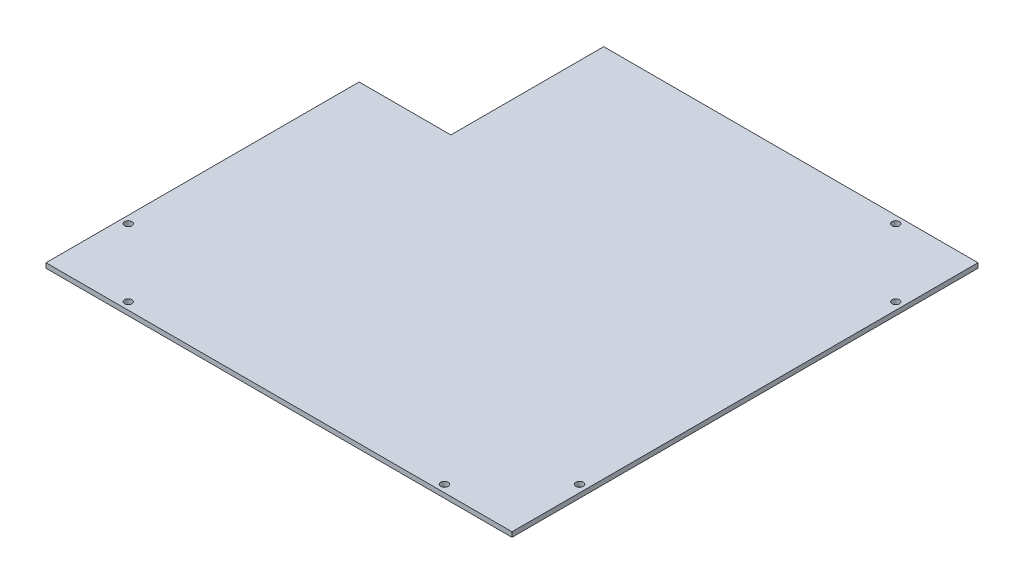
from build123d import *

# Parameters (mm, degrees)
SKETCH1_W           = 152.4
SKETCH1_H           = 152.4
SKETCH1_R           = 1.2
BOSS_EXTRUDE1_DEPTH = 1.5748
SKETCH2_W           = 30
SKETCH2_H           = 50
CUT_EXTRUDE1_DEPTH  = 2.5748


with BuildPart() as part:
    # Sketch1 → Boss-Extrude1 (new body)
    with BuildSketch(Plane(origin=(0, 0, 0), x_dir=(1, 0, 0), z_dir=(0, 1, 0))):
        Rectangle(SKETCH1_W, SKETCH1_H)
        with Locations((-51.7, 73.8)):
            Circle(SKETCH1_R, mode=Mode.SUBTRACT)
        with Locations((51.7, 73.8)):
            Circle(SKETCH1_R, mode=Mode.SUBTRACT)
        with Locations((73.8, 51.7)):
            Circle(SKETCH1_R, mode=Mode.SUBTRACT)
        with Locations((73.8, -51.7)):
            Circle(SKETCH1_R, mode=Mode.SUBTRACT)
        with Locations((-73.8, -51.7)):
            Circle(SKETCH1_R, mode=Mode.SUBTRACT)
        with Locations((-73.8, 51.7)):
            Circle(SKETCH1_R, mode=Mode.SUBTRACT)
        with Locations((-51.7, -73.8)):
            Circle(SKETCH1_R, mode=Mode.SUBTRACT)
        with Locations((51.7, -73.8)):
            Circle(SKETCH1_R, mode=Mode.SUBTRACT)
    extrude(amount=BOSS_EXTRUDE1_DEPTH)

    # Sketch2 → Cut-Extrude1 (cut, through all)
    with BuildSketch(Plane(origin=(0, 1.5748, 0), x_dir=(1, 0, 0), z_dir=(0, 1, 0))):
        with Locations((-61.2, 51.2)):
            Rectangle(SKETCH2_W, SKETCH2_H)
    extrude(amount=-CUT_EXTRUDE1_DEPTH, mode=Mode.SUBTRACT)


solid = part.part
